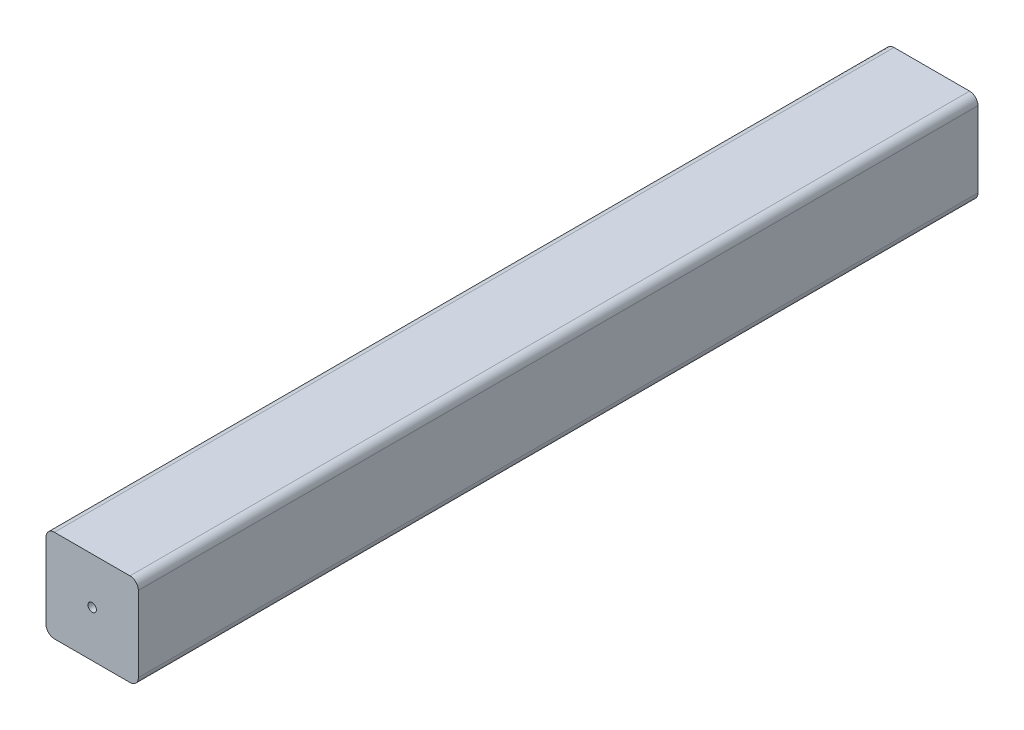
from build123d import *

# Parameters (mm, degrees)
ESQUISSE1_R      = 1
EXTRUSION1_DEPTH = 200


with BuildPart() as part:
    # Esquisse1 → Extrusion1 (new body)
    with BuildSketch(Plane.XY):
        with BuildLine():
            Line((-9, 11), (9, 11))
            ThreePointArc((9, 11), (10.414213562, 10.414213562), (11, 9))
            Line((11, 9), (11, -9))
            ThreePointArc((11, -9), (10.414213562, -10.414213562), (9, -11))
            Line((9, -11), (-9, -11))
            ThreePointArc((-9, -11), (-10.414213562, -10.414213562), (-11, -9))
            Line((-11, -9), (-11, 9))
            ThreePointArc((-11, 9), (-10.414213562, 10.414213562), (-9, 11))
        make_face()
        Circle(ESQUISSE1_R, mode=Mode.SUBTRACT)
    extrude(amount=EXTRUSION1_DEPTH)


solid = part.part
